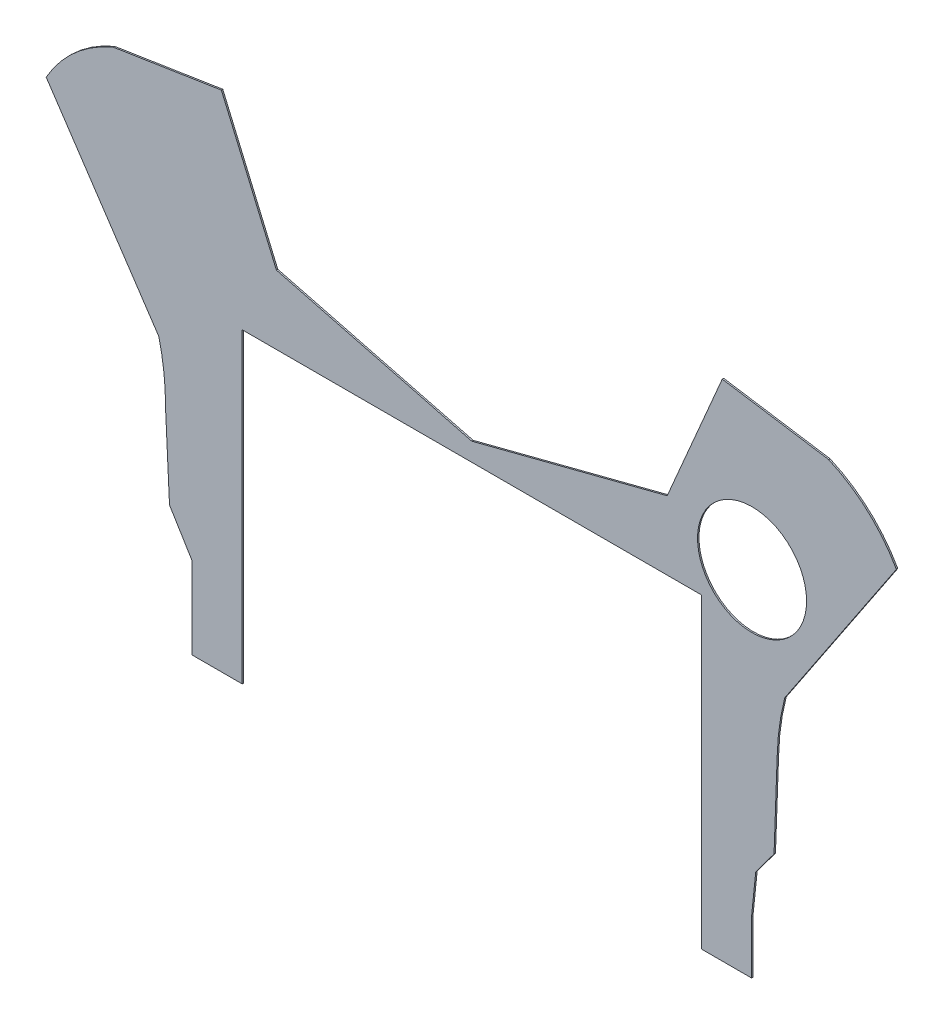
from build123d import *

# Parameters (mm, degrees)
MODEL_R                 = 3.800728286
SALIENTE_EXTRUIR1_DEPTH = 0.1


with BuildPart() as part:
    # Model → Saliente-Extruir1 (new body)
    with BuildSketch(Plane.XY):
        with BuildLine():
            Line((13.692923281, 36.409278797), (9.778554106, 35.797482596))
            Line((9.778554106, 35.797482596), (9.291241734, 35.721318124))
            ThreePointArc((9.291241734, 35.721318124), (6.601579479, 34.038755415), (4.608572881, 31.570309544))
            Line((4.608572881, 31.570309544), (12.45581545, 19.849854112))
            ThreePointArc((12.45581545, 19.849854112), (12.812940227, 17.870349583), (12.922946265, 15.861898697))
            Line((12.922946265, 15.861898697), (13.203519251, 10.044821535))
            Line((13.203519251, 10.044821535), (14.770932303, 7.477024351))
            Line((14.770932303, 7.477024351), (14.770932303, 4.477024351))
            Line((14.770932303, 4.477024351), (14.770932303, 1.777024351))
            Line((14.770932303, 1.777024351), (18.272189759, 1.777024351))
            Line((18.272189759, 1.777024351), (18.272189759, 23.155058368))
            Line((18.272189759, 23.155058368), (33.772189759, 23.155058368))
            Line((33.772189759, 23.155058368), (34.772189759, 23.155058368))
            Line((34.772189759, 23.155058368), (50.272189759, 23.155058368))
            Line((50.272189759, 23.155058368), (50.272189759, 1.777024351))
            Line((50.272189759, 1.777024351), (53.770932303, 1.775742122))
            Line((53.770932303, 1.775742122), (53.770932303, 5.477024351))
            Line((53.770932303, 5.477024351), (54.065641416, 8.331670065))
            Line((54.065641416, 8.331670065), (55.340860267, 10.044821535))
            Line((55.340860267, 10.044821535), (55.55942352, 16.069253716))
            ThreePointArc((55.55942352, 16.069253716), (55.715346099, 17.974760468), (56.088564069, 19.849854112))
            Line((56.088564069, 19.849854112), (63.866724949, 31.491817154))
            ThreePointArc((63.866724949, 31.491817154), (61.853109226, 34.011935883), (59.141967464, 35.759893842))
            Line((59.141967464, 35.759893842), (51.731314314, 36.906395207))
            Line((51.731314314, 36.906395207), (47.893743211, 27.949013218))
            Line((47.893743211, 27.949013218), (34.272189759, 24.431748181))
            Line((34.272189759, 24.431748181), (20.650636308, 27.949013218))
            Line((20.650636308, 27.949013218), (16.81686132, 36.89753459))
            Line((16.81686132, 36.89753459), (13.692923281, 36.409278797))
        make_face()
        with Locations((53.808865901, 26.441300342)):
            Circle(MODEL_R, mode=Mode.SUBTRACT)
    extrude(amount=SALIENTE_EXTRUIR1_DEPTH)


solid = part.part
